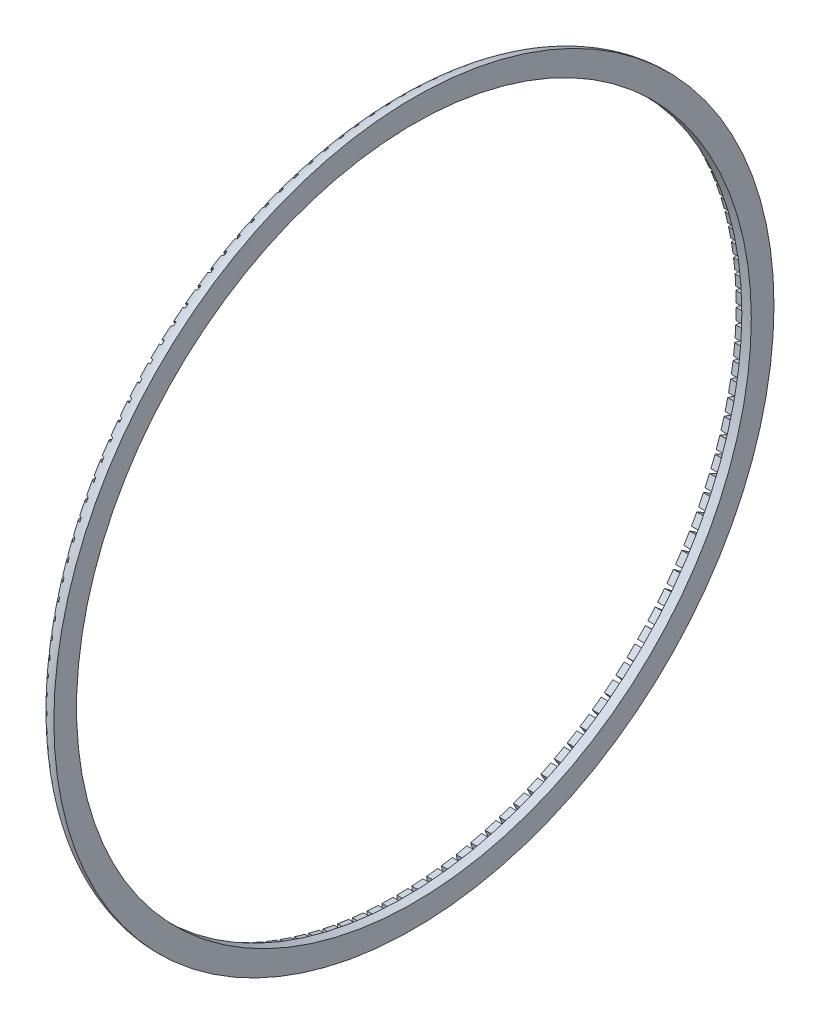
from build123d import *

# Parameters (mm, degrees)
CUT_EXTRUDE1_DEPTH = 3


with BuildPart() as part:
    # Sketch1 → Revolve1 (revolve)
    with BuildSketch(Plane.XY):
        with BuildLine():
            Line((-17.495417101, 23.232569393), (-16.995417101, 23.232569393))
            Line((-16.995417101, 23.232569393), (-16.995417101, 23.032569393))
            Line((-16.995417101, 23.032569393), (-16.495417101, 23.032569393))
            Line((-16.495417101, 23.032569393), (-16.495417101, 24.232569393))
            ThreePointArc((-16.495417101, 24.232569393), (-17.202523882, 23.939676175), (-17.495417101, 23.232569393))
        make_face()
    revolve(axis=Axis((-9.495417101, 5.185065564, 0), (-1, 0, 0)))

    # Sketch2 → Cut-Extrude1 (cut)
    with BuildSketch(Plane(origin=(-20, 0, 0), x_dir=(0, 0, -1), z_dir=(1, 0, 0))):
        with BuildLine():
            Line((0.1, 24.232569393), (0.1, 23.227252678))
            ThreePointArc((0.1, 23.227252678), (0, 23.127252678), (-0.1, 23.227252678))
            Line((-0.1, 23.227252678), (-0.1, 24.232569393))
            ThreePointArc((-0.1, 24.232569393), (0, 24.332569393), (0.1, 24.232569393))
        make_face()
        with BuildLine():
            Line((0.93074527, 24.210078452), (0.886893971, 23.205718575))
            ThreePointArc((0.886893971, 23.205718575), (0.78262721, 23.110175692), (0.687084326, 23.214442453))
            Line((0.687084326, 23.214442453), (0.730935626, 24.218802329))
            ThreePointArc((0.730935626, 24.218802329), (0.835202387, 24.314345212), (0.93074527, 24.210078452))
        make_face()
        with BuildLine():
            Line((1.759718814, 24.151372316), (1.672099689, 23.149881135))
            ThreePointArc((1.672099689, 23.149881135), (1.563764644, 23.058977239), (1.472860749, 23.167312283))
            Line((1.472860749, 23.167312283), (1.560479874, 24.168803465))
            ThreePointArc((1.560479874, 24.168803465), (1.668814918, 24.259707361), (1.759718814, 24.151372316))
        make_face()
        with BuildLine():
            Line((2.585342632, 24.056562738), (2.454122469, 23.059846647))
            ThreePointArc((2.454122469, 23.059846647), (2.341925364, 22.97375478), (2.255833497, 23.085951885))
            Line((2.255833497, 23.085951885), (2.38705366, 24.082667977))
            ThreePointArc((2.38705366, 24.082667977), (2.499250765, 24.168759844), (2.585342632, 24.056562738))
        make_face()
        with BuildLine():
            Line((3.406045104, 23.925830193), (3.231473689, 22.935786498))
            ThreePointArc((3.231473689, 22.935786498), (3.115628096, 22.85467054), (3.034512138, 22.970516133))
            Line((3.034512138, 22.970516133), (3.209083554, 23.960559828))
            ThreePointArc((3.209083554, 23.960559828), (3.324929147, 24.041675786), (3.406045104, 23.925830193))
        make_face()
        with BuildLine():
            Line((4.220263976, 23.759423537), (4.002673614, 22.777936842))
            ThreePointArc((4.002673614, 22.777936842), (3.883400052, 22.701951203), (3.807414413, 22.821224765))
            Line((3.807414413, 22.821224765), (4.025004775, 23.80271146))
            ThreePointArc((4.025004775, 23.80271146), (4.144278337, 23.878697099), (4.220263976, 23.759423537))
        make_face()
        with BuildLine():
            Line((5.026449335, 23.557659535), (4.766254223, 22.586598156))
            ThreePointArc((4.766254223, 22.586598156), (4.643779736, 22.515887478), (4.573069058, 22.638361965))
            Line((4.573069058, 22.638361965), (4.83326417, 23.609423344))
            ThreePointArc((4.83326417, 23.609423344), (4.955738657, 23.680134022), (5.026449335, 23.557659535))
        make_face()
        with BuildLine():
            Line((5.823066563, 23.320922256), (5.520761996, 22.362134663))
            ThreePointArc((5.520761996, 22.362134663), (5.395319721, 22.296833548), (5.330018606, 22.422275823))
            Line((5.330018606, 22.422275823), (5.632323173, 23.381063415))
            ThreePointArc((5.632323173, 23.381063415), (5.757765448, 23.446364531), (5.823066563, 23.320922256))
        make_face()
        with BuildLine():
            Line((6.608599252, 23.049662343), (6.264760685, 22.104973644))
            ThreePointArc((6.264760685, 22.104973644), (6.136589408, 22.045206396), (6.076822161, 22.173377672))
            Line((6.076822161, 22.173377672), (6.420660728, 23.118066371))
            ThreePointArc((6.420660728, 23.118066371), (6.548832004, 23.177833619), (6.608599252, 23.049662343))
        make_face()
        with BuildLine():
            Line((7.381552097, 22.744396154), (6.996834046, 21.815604617))
            ThreePointArc((6.996834046, 21.815604617), (6.866177749, 21.761485007), (6.812058139, 21.892141304))
            Line((6.812058139, 21.892141304), (7.19677619, 22.820932841))
            ThreePointArc((7.19677619, 22.820932841), (7.327432487, 22.875052451), (7.381552097, 22.744396154))
        make_face()
        with BuildLine():
            Line((8.140453738, 22.405704782), (7.715588535, 21.494578415))
            ThreePointArc((7.715588535, 21.494578415), (7.58269593, 21.446209462), (7.534326978, 21.579102067))
            Line((7.534326978, 21.579102067), (7.95919218, 22.490228434))
            ThreePointArc((7.95919218, 22.490228434), (8.092084785, 22.538597387), (8.140453738, 22.405704782))
        make_face()
        with BuildLine():
            Line((8.883859562, 22.034232944), (8.419655963, 21.142506127))
            ThreePointArc((8.419655963, 21.142506127), (8.284780018, 21.099979905), (8.242253796, 21.23485585))
            Line((8.242253796, 21.23485585), (8.706457396, 22.126582667))
            ThreePointArc((8.706457396, 22.126582667), (8.84133334, 22.169108889), (8.883859562, 22.034232944))
        make_face()
        with BuildLine():
            Line((9.610354455, 21.630687759), (9.107696098, 20.760057945))
            ThreePointArc((9.107696098, 20.760057945), (8.971093557, 20.723455404), (8.934491017, 20.860057945))
            Line((8.934491017, 20.860057945), (9.437149374, 21.730687759))
            ThreePointArc((9.437149374, 21.730687759), (9.573751915, 21.767290299), (9.610354455, 21.630687759))
        make_face()
        with BuildLine():
            Line((10.318555492, 21.195837397), (9.778399215, 20.347961879))
            ThreePointArc((9.778399215, 20.347961879), (9.640330109, 20.317352695), (9.609720926, 20.455421801))
            Line((9.609720926, 20.455421801), (10.149877203, 21.303297319))
            ThreePointArc((10.149877203, 21.303297319), (10.287946308, 21.333906502), (10.318555492, 21.195837397))
        make_face()
        with BuildLine():
            Line((11.007114572, 20.730509621), (10.430488593, 19.907002378))
            ThreePointArc((10.430488593, 19.907002378), (10.291215745, 19.882444818), (10.266658185, 20.021717666))
            Line((10.266658185, 20.021717666), (10.843284163, 20.845224908))
            ThreePointArc((10.843284163, 20.845224908), (10.982557012, 20.869782469), (11.007114572, 20.730509621))
        make_face()
        with BuildLine():
            Line((11.674720984, 20.235590208), (11.062722944, 19.438018834))
            ThreePointArc((11.062722944, 19.438018834), (10.922511467, 19.419559643), (10.904052276, 19.55977112))
            Line((10.904052276, 19.55977112), (11.516050316, 20.357342494))
            ThreePointArc((11.516050316, 20.357342494), (11.656261793, 20.375801685), (11.674720984, 20.235590208))
        make_face()
        with BuildLine():
            Line((12.320103901, 19.712021267), (11.673898773, 18.941903983))
            ThreePointArc((11.673898773, 18.941903983), (11.533015568, 18.9295783), (11.520689884, 19.070461505))
            Line((11.520689884, 19.070461505), (12.166895013, 19.840578789))
            ThreePointArc((12.166895013, 19.840578789), (12.307778218, 19.852904472), (12.320103901, 19.712021267))
        make_face()
        with BuildLine():
            Line((12.9420348, 19.160799439), (12.262852672, 18.419602209))
            ThreePointArc((12.262852672, 18.419602209), (12.121565918, 18.413433496), (12.115397205, 18.55472025))
            Line((12.115397205, 18.55472025), (12.794579333, 19.295917481))
            ThreePointArc((12.794579333, 19.295917481), (12.935866088, 19.302086194), (12.9420348, 19.160799439))
        make_face()
        with BuildLine():
            Line((13.539329801, 18.582974008), (12.828463534, 17.872107742))
            ThreePointArc((12.828463534, 17.872107742), (12.687042178, 17.872107742), (12.687042178, 18.013529098))
            Line((12.687042178, 18.013529098), (13.397908444, 18.724395365))
            ThreePointArc((13.397908444, 18.724395365), (13.539329801, 18.724395365), (13.539329801, 18.582974008))
        make_face()
        with BuildLine():
            Line((14.110851917, 17.979644897), (13.369654687, 17.300462769))
            ThreePointArc((13.369654687, 17.300462769), (13.228367932, 17.306631481), (13.234536645, 17.447918236))
            Line((13.234536645, 17.447918236), (13.975733876, 18.127100364))
            ThreePointArc((13.975733876, 18.127100364), (14.11702063, 18.120931651), (14.110851917, 17.979644897))
        make_face()
        with BuildLine():
            Line((14.655513225, 17.351960577), (13.885395942, 16.705755448))
            ThreePointArc((13.885395942, 16.705755448), (13.744512736, 16.718081132), (13.75683842, 16.858964337))
            Line((13.75683842, 16.858964337), (14.526955703, 17.505169465))
            ThreePointArc((14.526955703, 17.505169465), (14.667838908, 17.492843782), (14.655513225, 17.351960577))
        make_face()
        with BuildLine():
            Line((15.17227693, 16.70111588), (14.374705556, 16.08911784))
            ThreePointArc((14.374705556, 16.08911784), (14.234494079, 16.107577031), (14.25295327, 16.247788508))
            Line((14.25295327, 16.247788508), (15.050524644, 16.859786548))
            ThreePointArc((15.050524644, 16.859786548), (15.190736121, 16.841327357), (15.17227693, 16.70111588))
        make_face()
        with BuildLine():
            Line((15.660159344, 16.028349727), (14.836652102, 15.451723748))
            ThreePointArc((14.836652102, 15.451723748), (14.697379254, 15.476281309), (14.721936814, 15.615554157))
            Line((14.721936814, 15.615554157), (15.545444057, 16.192180136))
            ThreePointArc((15.545444057, 16.192180136), (15.684716905, 16.167622575), (15.660159344, 16.028349727))
        make_face()
        with BuildLine():
            Line((16.118231755, 15.334942767), (15.270356237, 14.794786489))
            ThreePointArc((15.270356237, 14.794786489), (15.132287131, 14.825395673), (15.162896315, 14.963464779))
            Line((15.162896315, 14.963464779), (16.010771833, 15.503621056))
            ThreePointArc((16.010771833, 15.503621056), (16.148840938, 15.473011872), (16.118231755, 15.334942767))
        make_face()
        with BuildLine():
            Line((16.545622195, 14.622214938), (15.674992381, 14.119556581))
            ThreePointArc((15.674992381, 14.119556581), (15.53838984, 14.156159121), (15.574992381, 14.292761661))
            Line((15.574992381, 14.292761661), (16.445622195, 14.795420019))
            ThreePointArc((16.445622195, 14.795420019), (16.582224735, 14.758817479), (16.545622195, 14.622214938))
        make_face()
        with BuildLine():
            Line((16.941517103, 13.891522959), (16.049790286, 13.42731936))
            ThreePointArc((16.049790286, 13.42731936), (15.914914341, 13.469845582), (15.957440563, 13.604721527))
            Line((15.957440563, 13.604721527), (16.84916738, 14.068925126))
            ThreePointArc((16.84916738, 14.068925126), (16.984043325, 14.026398904), (16.941517103, 13.891522959))
        make_face()
        with BuildLine():
            Line((17.30516287, 13.144257744), (16.394036503, 12.719392541))
            ThreePointArc((16.394036503, 12.719392541), (16.261143898, 12.767761494), (16.309512851, 12.900654099))
            Line((16.309512851, 12.900654099), (17.220639218, 13.325519302))
            ThreePointArc((17.220639218, 13.325519302), (17.353531823, 13.277150349), (17.30516287, 13.144257744))
        make_face()
        with BuildLine():
            Line((17.635867277, 12.381841754), (16.70707574, 11.997123703))
            ThreePointArc((16.70707574, 11.997123703), (16.576419443, 12.051243313), (16.630539053, 12.181899609))
            Line((16.630539053, 12.181899609), (17.55933059, 12.566617661))
            ThreePointArc((17.55933059, 12.566617661), (17.689986887, 12.512498051), (17.635867277, 12.381841754))
        make_face()
        with BuildLine():
            Line((17.933000807, 11.605726292), (16.988312108, 11.261887725))
            ThreePointArc((16.988312108, 11.261887725), (16.860140832, 11.321654972), (16.91990808, 11.449826249))
            Line((16.91990808, 11.449826249), (17.864596779, 11.793664816))
            ThreePointArc((17.864596779, 11.793664816), (17.992768055, 11.733897568), (17.933000807, 11.605726292))
        make_face()
        with BuildLine():
            Line((18.195997852, 10.817388736), (17.237210259, 10.51508417))
            ThreePointArc((17.237210259, 10.51508417), (17.111767984, 10.580385285), (17.177069099, 10.70582756))
            Line((17.177069099, 10.70582756), (18.135856692, 11.008132127))
            ThreePointArc((18.135856692, 11.008132127), (18.261298967, 10.942831011), (18.195997852, 10.817388736))
        make_face()
        with BuildLine():
            Line((18.42435778, 10.018329734), (17.453296401, 9.758134622))
            ThreePointArc((17.453296401, 9.758134622), (17.330821914, 9.8288453), (17.401532592, 9.951319787))
            Line((17.401532592, 9.951319787), (18.372593971, 10.211514899))
            ThreePointArc((18.372593971, 10.211514899), (18.495068458, 10.140804221), (18.42435778, 10.018329734))
        make_face()
        with BuildLine():
            Line((18.617645896, 9.210070339), (17.636159201, 8.992479977))
            ThreePointArc((17.636159201, 8.992479977), (17.516885639, 9.068465616), (17.592871278, 9.187739178))
            Line((17.592871278, 9.187739178), (18.574357973, 9.40532954))
            ThreePointArc((18.574357973, 9.40532954), (18.693631535, 9.329343901), (18.617645896, 9.210070339))
        make_face()
        with BuildLine():
            Line((18.775494265, 8.394149118), (17.785450569, 8.219577702))
            ThreePointArc((17.785450569, 8.219577702), (17.669604976, 8.30069366), (17.750720934, 8.416539253))
            Line((17.750720934, 8.416539253), (18.740764629, 8.591110668))
            ThreePointArc((18.740764629, 8.591110668), (18.856610222, 8.509994711), (18.775494265, 8.394149118))
        make_face()
        with BuildLine():
            Line((18.897602413, 7.572119224), (17.900886322, 7.440899061))
            ThreePointArc((17.900886322, 7.440899061), (17.788689216, 7.526990928), (17.874781083, 7.639188033))
            Line((17.874781083, 7.639188033), (18.871497175, 7.770408196))
            ThreePointArc((18.871497175, 7.770408196), (18.98369428, 7.684316329), (18.897602413, 7.572119224))
        make_face()
        with BuildLine():
            Line((18.983737901, 6.745545438), (17.982246719, 6.657926313))
            ThreePointArc((17.982246719, 6.657926313), (17.873911675, 6.748830208), (17.964815571, 6.857165252))
            Line((17.964815571, 6.857165252), (18.966306753, 6.944784377))
            ThreePointArc((18.966306753, 6.944784377), (19.074641797, 6.853880482), (18.983737901, 6.745545438))
        make_face()
        with BuildLine():
            Line((19.033736765, 5.91600119), (18.029376889, 5.87214989))
            ThreePointArc((18.029376889, 5.87214989), (17.925110128, 5.967692774), (18.020653011, 6.071959535))
            Line((18.020653011, 6.071959535), (19.025012888, 6.115810834))
            ThreePointArc((19.025012888, 6.115810834), (19.129279649, 6.02026795), (19.033736765, 5.91600119))
        make_face()
        with BuildLine():
            Line((19.04750383, 5.085065564), (18.042187114, 5.085065564))
            ThreePointArc((18.042187114, 5.085065564), (17.942187114, 5.185065564), (18.042187114, 5.285065564))
            Line((18.042187114, 5.285065564), (19.04750383, 5.285065564))
            ThreePointArc((19.04750383, 5.285065564), (19.14750383, 5.185065564), (19.04750383, 5.085065564))
        make_face()
        with BuildLine():
            Line((19.025012888, 4.254320294), (18.020653011, 4.298171593))
            ThreePointArc((18.020653011, 4.298171593), (17.925110128, 4.402438354), (18.029376889, 4.497981237))
            Line((18.029376889, 4.497981237), (19.033736765, 4.454129938))
            ThreePointArc((19.033736765, 4.454129938), (19.129279649, 4.349863177), (19.025012888, 4.254320294))
        make_face()
        with BuildLine():
            Line((18.966306753, 3.42534675), (17.964815571, 3.512965875))
            ThreePointArc((17.964815571, 3.512965875), (17.873911675, 3.621300919), (17.982246719, 3.712204815))
            Line((17.982246719, 3.712204815), (18.983737901, 3.62458569))
            ThreePointArc((18.983737901, 3.62458569), (19.074641797, 3.516250646), (18.966306753, 3.42534675))
        make_face()
        with BuildLine():
            Line((18.871497175, 2.599722932), (17.874781083, 2.730943094))
            ThreePointArc((17.874781083, 2.730943094), (17.788689216, 2.8431402), (17.900886322, 2.929232067))
            Line((17.900886322, 2.929232067), (18.897602413, 2.798011904))
            ThreePointArc((18.897602413, 2.798011904), (18.98369428, 2.685814798), (18.871497175, 2.599722932))
        make_face()
        with BuildLine():
            Line((18.740764629, 1.779020459), (17.750720934, 1.953591875))
            ThreePointArc((17.750720934, 1.953591875), (17.669604976, 2.069437468), (17.785450569, 2.150553426))
            Line((17.785450569, 2.150553426), (18.775494265, 1.97598201))
            ThreePointArc((18.775494265, 1.97598201), (18.856610222, 1.860136417), (18.740764629, 1.779020459))
        make_face()
        with BuildLine():
            Line((18.574357973, 0.964801588), (17.592871278, 1.18239195))
            ThreePointArc((17.592871278, 1.18239195), (17.516885639, 1.301665512), (17.636159201, 1.377651151))
            Line((17.636159201, 1.377651151), (18.617645896, 1.160060789))
            ThreePointArc((18.617645896, 1.160060789), (18.693631535, 1.040787227), (18.574357973, 0.964801588))
        make_face()
        with BuildLine():
            Line((18.372593971, 0.158616228), (17.401532592, 0.418811341))
            ThreePointArc((17.401532592, 0.418811341), (17.330821914, 0.541285828), (17.453296401, 0.611996506))
            Line((17.453296401, 0.611996506), (18.42435778, 0.351801394))
            ThreePointArc((18.42435778, 0.351801394), (18.495068458, 0.229326907), (18.372593971, 0.158616228))
        make_face()
        with BuildLine():
            Line((18.135856692, -0.638000999), (17.177069099, -0.335696432))
            ThreePointArc((17.177069099, -0.335696432), (17.111767984, -0.210254157), (17.237210259, -0.144953042))
            Line((17.237210259, -0.144953042), (18.195997852, -0.447257609))
            ThreePointArc((18.195997852, -0.447257609), (18.261298967, -0.572699884), (18.135856692, -0.638000999))
        make_face()
        with BuildLine():
            Line((17.864596779, -1.423533688), (16.91990808, -1.079695121))
            ThreePointArc((16.91990808, -1.079695121), (16.860140832, -0.951523845), (16.988312108, -0.891756597))
            Line((16.988312108, -0.891756597), (17.933000807, -1.235595164))
            ThreePointArc((17.933000807, -1.235595164), (17.992768055, -1.36376644), (17.864596779, -1.423533688))
        make_face()
        with BuildLine():
            Line((17.55933059, -2.196486533), (16.630539053, -1.811768482))
            ThreePointArc((16.630539053, -1.811768482), (16.576419443, -1.681112185), (16.70707574, -1.626992575))
            Line((16.70707574, -1.626992575), (17.635867277, -2.011710626))
            ThreePointArc((17.635867277, -2.011710626), (17.689986887, -2.142366923), (17.55933059, -2.196486533))
        make_face()
        with BuildLine():
            Line((17.220639218, -2.955388174), (16.309512851, -2.530522971))
            ThreePointArc((16.309512851, -2.530522971), (16.261143898, -2.397630366), (16.394036503, -2.349261414))
            Line((16.394036503, -2.349261414), (17.30516287, -2.774126616))
            ThreePointArc((17.30516287, -2.774126616), (17.353531823, -2.907019221), (17.220639218, -2.955388174))
        make_face()
        with BuildLine():
            Line((16.84916738, -3.698793998), (15.957440563, -3.234590399))
            ThreePointArc((15.957440563, -3.234590399), (15.914914341, -3.099714455), (16.049790286, -3.057188233))
            Line((16.049790286, -3.057188233), (16.941517103, -3.521391832))
            ThreePointArc((16.941517103, -3.521391832), (16.984043325, -3.656267776), (16.84916738, -3.698793998))
        make_face()
        with BuildLine():
            Line((16.445622195, -4.425288891), (15.574992381, -3.922630534))
            ThreePointArc((15.574992381, -3.922630534), (15.53838984, -3.786027993), (15.674992381, -3.749425453))
            Line((15.674992381, -3.749425453), (16.545622195, -4.252083811))
            ThreePointArc((16.545622195, -4.252083811), (16.582224735, -4.388686351), (16.445622195, -4.425288891))
        make_face()
        with BuildLine():
            Line((16.010771833, -5.133489928), (15.162896315, -4.593333651))
            ThreePointArc((15.162896315, -4.593333651), (15.132287131, -4.455264546), (15.270356237, -4.424655362))
            Line((15.270356237, -4.424655362), (16.118231755, -4.964811639))
            ThreePointArc((16.118231755, -4.964811639), (16.148840938, -5.102880745), (16.010771833, -5.133489928))
        make_face()
        with BuildLine():
            Line((15.545444057, -5.822049008), (14.721936814, -5.24542303))
            ThreePointArc((14.721936814, -5.24542303), (14.697379254, -5.106150181), (14.836652102, -5.081592621))
            Line((14.836652102, -5.081592621), (15.660159344, -5.6582186))
            ThreePointArc((15.660159344, -5.6582186), (15.684716905, -5.797491448), (15.545444057, -5.822049008))
        make_face()
        with BuildLine():
            Line((15.050524644, -6.48965542), (14.25295327, -5.87765738))
            ThreePointArc((14.25295327, -5.87765738), (14.234494079, -5.737445903), (14.374705556, -5.718986712))
            Line((14.374705556, -5.718986712), (15.17227693, -6.330984752))
            ThreePointArc((15.17227693, -6.330984752), (15.190736121, -6.471196229), (15.050524644, -6.48965542))
        make_face()
        with BuildLine():
            Line((14.526955703, -7.135038338), (13.75683842, -6.488833209))
            ThreePointArc((13.75683842, -6.488833209), (13.744512736, -6.347950004), (13.885395942, -6.335624321))
            Line((13.885395942, -6.335624321), (14.655513225, -6.981829449))
            ThreePointArc((14.655513225, -6.981829449), (14.667838908, -7.122712654), (14.526955703, -7.135038338))
        make_face()
        with BuildLine():
            Line((13.975733876, -7.756969237), (13.234536645, -7.077787108))
            ThreePointArc((13.234536645, -7.077787108), (13.228367932, -6.936500354), (13.369654687, -6.930331641))
            Line((13.369654687, -6.930331641), (14.110851917, -7.609513769))
            ThreePointArc((14.110851917, -7.609513769), (14.11702063, -7.750800524), (13.975733876, -7.756969237))
        make_face()
        with BuildLine():
            Line((13.397908444, -8.354264237), (12.687042178, -7.64339797))
            ThreePointArc((12.687042178, -7.64339797), (12.687042178, -7.501976614), (12.828463534, -7.501976614))
            Line((12.828463534, -7.501976614), (13.539329801, -8.212842881))
            ThreePointArc((13.539329801, -8.212842881), (13.539329801, -8.354264237), (13.397908444, -8.354264237))
        make_face()
        with BuildLine():
            Line((12.794579333, -8.925786353), (12.115397205, -8.184589123))
            ThreePointArc((12.115397205, -8.184589123), (12.121565918, -8.043302368), (12.262852672, -8.049471081))
            Line((12.262852672, -8.049471081), (12.9420348, -8.790668312))
            ThreePointArc((12.9420348, -8.790668312), (12.935866088, -8.931955066), (12.794579333, -8.925786353))
        make_face()
        with BuildLine():
            Line((12.166895013, -9.470447661), (11.520689884, -8.700330378))
            ThreePointArc((11.520689884, -8.700330378), (11.533015568, -8.559447172), (11.673898773, -8.571772856))
            Line((11.673898773, -8.571772856), (12.320103901, -9.341890139))
            ThreePointArc((12.320103901, -9.341890139), (12.307778218, -9.482773344), (12.166895013, -9.470447661))
        make_face()
        with BuildLine():
            Line((11.516050316, -9.987211366), (10.904052276, -9.189639992))
            ThreePointArc((10.904052276, -9.189639992), (10.922511467, -9.049428515), (11.062722944, -9.067887706))
            Line((11.062722944, -9.067887706), (11.674720984, -9.865459081))
            ThreePointArc((11.674720984, -9.865459081), (11.656261793, -10.005670558), (11.516050316, -9.987211366))
        make_face()
        with BuildLine():
            Line((10.843284163, -10.47509378), (10.266658185, -9.651586538))
            ThreePointArc((10.266658185, -9.651586538), (10.291215745, -9.51231369), (10.430488593, -9.536871251))
            Line((10.430488593, -9.536871251), (11.007114572, -10.360378493))
            ThreePointArc((11.007114572, -10.360378493), (10.982557012, -10.499651341), (10.843284163, -10.47509378))
        make_face()
        with BuildLine():
            Line((10.149877203, -10.933166191), (9.609720926, -10.085290673))
            ThreePointArc((9.609720926, -10.085290673), (9.640330109, -9.947221567), (9.778399215, -9.977830751))
            Line((9.778399215, -9.977830751), (10.318555492, -10.825706269))
            ThreePointArc((10.318555492, -10.825706269), (10.287946308, -10.963775375), (10.149877203, -10.933166191))
        make_face()
        with BuildLine():
            Line((9.437149374, -11.360556631), (8.934491017, -10.489926817))
            ThreePointArc((8.934491017, -10.489926817), (8.971093557, -10.353324277), (9.107696098, -10.389926817))
            Line((9.107696098, -10.389926817), (9.610354455, -11.260556631))
            ThreePointArc((9.610354455, -11.260556631), (9.573751915, -11.397159172), (9.437149374, -11.360556631))
        make_face()
        with BuildLine():
            Line((8.706457396, -11.756451539), (8.242253796, -10.864724722))
            ThreePointArc((8.242253796, -10.864724722), (8.284780018, -10.729848777), (8.419655963, -10.772374999))
            Line((8.419655963, -10.772374999), (8.883859562, -11.664101817))
            ThreePointArc((8.883859562, -11.664101817), (8.84133334, -11.798977761), (8.706457396, -11.756451539))
        make_face()
        with BuildLine():
            Line((7.95919218, -12.120097307), (7.534326978, -11.208970939))
            ThreePointArc((7.534326978, -11.208970939), (7.58269593, -11.076078334), (7.715588535, -11.124447287))
            Line((7.715588535, -11.124447287), (8.140453738, -12.035573654))
            ThreePointArc((8.140453738, -12.035573654), (8.092084785, -12.168466259), (7.95919218, -12.120097307))
        make_face()
        with BuildLine():
            Line((7.19677619, -12.450801713), (6.812058139, -11.522010176))
            ThreePointArc((6.812058139, -11.522010176), (6.866177749, -11.391353879), (6.996834046, -11.445473489))
            Line((6.996834046, -11.445473489), (7.381552097, -12.374265026))
            ThreePointArc((7.381552097, -12.374265026), (7.327432487, -12.504921323), (7.19677619, -12.450801713))
        make_face()
        with BuildLine():
            Line((6.420660728, -12.747935243), (6.076822161, -11.803246545))
            ThreePointArc((6.076822161, -11.803246545), (6.136589408, -11.675075268), (6.264760685, -11.734842516))
            Line((6.264760685, -11.734842516), (6.608599252, -12.679531215))
            ThreePointArc((6.608599252, -12.679531215), (6.548832004, -12.807702491), (6.420660728, -12.747935243))
        make_face()
        with BuildLine():
            Line((5.632323173, -13.010932288), (5.330018606, -12.052144696))
            ThreePointArc((5.330018606, -12.052144696), (5.395319721, -11.92670242), (5.520761996, -11.992003536))
            Line((5.520761996, -11.992003536), (5.823066563, -12.950791128))
            ThreePointArc((5.823066563, -12.950791128), (5.757765448, -13.076233403), (5.632323173, -13.010932288))
        make_face()
        with BuildLine():
            Line((4.83326417, -13.239292216), (4.573069058, -12.268230837))
            ThreePointArc((4.573069058, -12.268230837), (4.643779736, -12.14575635), (4.766254223, -12.216467028))
            Line((4.766254223, -12.216467028), (5.026449335, -13.187528407))
            ThreePointArc((5.026449335, -13.187528407), (4.955738657, -13.310002894), (4.83326417, -13.239292216))
        make_face()
        with BuildLine():
            Line((4.025004775, -13.432580332), (3.807414413, -12.451093637))
            ThreePointArc((3.807414413, -12.451093637), (3.883400052, -12.331820075), (4.002673614, -12.407805714))
            Line((4.002673614, -12.407805714), (4.220263976, -13.389292409))
            ThreePointArc((4.220263976, -13.389292409), (4.144278337, -13.508565971), (4.025004775, -13.432580332))
        make_face()
        with BuildLine():
            Line((3.209083554, -13.590428701), (3.034512138, -12.600385005))
            ThreePointArc((3.034512138, -12.600385005), (3.115628096, -12.484539412), (3.231473689, -12.56565537))
            Line((3.231473689, -12.56565537), (3.406045104, -13.555699065))
            ThreePointArc((3.406045104, -13.555699065), (3.324929147, -13.671544658), (3.209083554, -13.590428701))
        make_face()
        with BuildLine():
            Line((2.38705366, -13.712536849), (2.255833497, -12.715820758))
            ThreePointArc((2.255833497, -12.715820758), (2.341925364, -12.603623652), (2.454122469, -12.689715519))
            Line((2.454122469, -12.689715519), (2.585342632, -13.686431611))
            ThreePointArc((2.585342632, -13.686431611), (2.499250765, -13.798628716), (2.38705366, -13.712536849))
        make_face()
        with BuildLine():
            Line((1.560479874, -13.798672337), (1.472860749, -12.797181156))
            ThreePointArc((1.472860749, -12.797181156), (1.563764644, -12.688846112), (1.672099689, -12.779750007))
            Line((1.672099689, -12.779750007), (1.759718814, -13.781241189))
            ThreePointArc((1.759718814, -13.781241189), (1.668814918, -13.889576233), (1.560479874, -13.798672337))
        make_face()
        with BuildLine():
            Line((0.730935626, -13.848671201), (0.687084326, -12.844311325))
            ThreePointArc((0.687084326, -12.844311325), (0.78262721, -12.740044564), (0.886893971, -12.835587447))
            Line((0.886893971, -12.835587447), (0.93074527, -13.839947324))
            ThreePointArc((0.93074527, -13.839947324), (0.835202387, -13.944214085), (0.730935626, -13.848671201))
        make_face()
        with BuildLine():
            Line((-0.1, -13.862438266), (-0.1, -12.85712155))
            ThreePointArc((-0.1, -12.85712155), (0, -12.75712155), (0.1, -12.85712155))
            Line((0.1, -12.85712155), (0.1, -13.862438266))
            ThreePointArc((0.1, -13.862438266), (0, -13.962438266), (-0.1, -13.862438266))
        make_face()
        with BuildLine():
            Line((-0.93074527, -13.839947324), (-0.886893971, -12.835587447))
            ThreePointArc((-0.886893971, -12.835587447), (-0.78262721, -12.740044564), (-0.687084326, -12.844311325))
            Line((-0.687084326, -12.844311325), (-0.730935626, -13.848671201))
            ThreePointArc((-0.730935626, -13.848671201), (-0.835202387, -13.944214085), (-0.93074527, -13.839947324))
        make_face()
        with BuildLine():
            Line((-1.759718814, -13.781241189), (-1.672099689, -12.779750007))
            ThreePointArc((-1.672099689, -12.779750007), (-1.563764644, -12.688846112), (-1.472860749, -12.797181156))
            Line((-1.472860749, -12.797181156), (-1.560479874, -13.798672337))
            ThreePointArc((-1.560479874, -13.798672337), (-1.668814918, -13.889576233), (-1.759718814, -13.781241189))
        make_face()
        with BuildLine():
            Line((-2.585342632, -13.686431611), (-2.454122469, -12.689715519))
            ThreePointArc((-2.454122469, -12.689715519), (-2.341925364, -12.603623652), (-2.255833497, -12.715820758))
            Line((-2.255833497, -12.715820758), (-2.38705366, -13.712536849))
            ThreePointArc((-2.38705366, -13.712536849), (-2.499250765, -13.798628716), (-2.585342632, -13.686431611))
        make_face()
        with BuildLine():
            Line((-3.406045104, -13.555699065), (-3.231473689, -12.56565537))
            ThreePointArc((-3.231473689, -12.56565537), (-3.115628096, -12.484539412), (-3.034512138, -12.600385005))
            Line((-3.034512138, -12.600385005), (-3.209083554, -13.590428701))
            ThreePointArc((-3.209083554, -13.590428701), (-3.324929147, -13.671544658), (-3.406045104, -13.555699065))
        make_face()
        with BuildLine():
            Line((-4.220263976, -13.389292409), (-4.002673614, -12.407805714))
            ThreePointArc((-4.002673614, -12.407805714), (-3.883400052, -12.331820075), (-3.807414413, -12.451093637))
            Line((-3.807414413, -12.451093637), (-4.025004775, -13.432580332))
            ThreePointArc((-4.025004775, -13.432580332), (-4.144278337, -13.508565971), (-4.220263976, -13.389292409))
        make_face()
        with BuildLine():
            Line((-5.026449335, -13.187528407), (-4.766254223, -12.216467028))
            ThreePointArc((-4.766254223, -12.216467028), (-4.643779736, -12.14575635), (-4.573069058, -12.268230837))
            Line((-4.573069058, -12.268230837), (-4.83326417, -13.239292216))
            ThreePointArc((-4.83326417, -13.239292216), (-4.955738657, -13.310002894), (-5.026449335, -13.187528407))
        make_face()
        with BuildLine():
            Line((-5.823066563, -12.950791128), (-5.520761996, -11.992003536))
            ThreePointArc((-5.520761996, -11.992003536), (-5.395319721, -11.92670242), (-5.330018606, -12.052144696))
            Line((-5.330018606, -12.052144696), (-5.632323173, -13.010932288))
            ThreePointArc((-5.632323173, -13.010932288), (-5.757765448, -13.076233403), (-5.823066563, -12.950791128))
        make_face()
        with BuildLine():
            Line((-6.608599252, -12.679531215), (-6.264760685, -11.734842516))
            ThreePointArc((-6.264760685, -11.734842516), (-6.136589408, -11.675075268), (-6.076822161, -11.803246545))
            Line((-6.076822161, -11.803246545), (-6.420660728, -12.747935243))
            ThreePointArc((-6.420660728, -12.747935243), (-6.548832004, -12.807702491), (-6.608599252, -12.679531215))
        make_face()
        with BuildLine():
            Line((-7.381552097, -12.374265026), (-6.996834046, -11.445473489))
            ThreePointArc((-6.996834046, -11.445473489), (-6.866177749, -11.391353879), (-6.812058139, -11.522010176))
            Line((-6.812058139, -11.522010176), (-7.19677619, -12.450801713))
            ThreePointArc((-7.19677619, -12.450801713), (-7.327432487, -12.504921323), (-7.381552097, -12.374265026))
        make_face()
        with BuildLine():
            Line((-8.140453738, -12.035573654), (-7.715588535, -11.124447287))
            ThreePointArc((-7.715588535, -11.124447287), (-7.58269593, -11.076078334), (-7.534326978, -11.208970939))
            Line((-7.534326978, -11.208970939), (-7.95919218, -12.120097307))
            ThreePointArc((-7.95919218, -12.120097307), (-8.092084785, -12.168466259), (-8.140453738, -12.035573654))
        make_face()
        with BuildLine():
            Line((-8.883859562, -11.664101817), (-8.419655963, -10.772374999))
            ThreePointArc((-8.419655963, -10.772374999), (-8.284780018, -10.729848777), (-8.242253796, -10.864724722))
            Line((-8.242253796, -10.864724722), (-8.706457396, -11.756451539))
            ThreePointArc((-8.706457396, -11.756451539), (-8.84133334, -11.798977761), (-8.883859562, -11.664101817))
        make_face()
        with BuildLine():
            Line((-9.610354455, -11.260556631), (-9.107696098, -10.389926817))
            ThreePointArc((-9.107696098, -10.389926817), (-8.971093557, -10.353324277), (-8.934491017, -10.489926817))
            Line((-8.934491017, -10.489926817), (-9.437149374, -11.360556631))
            ThreePointArc((-9.437149374, -11.360556631), (-9.573751915, -11.397159172), (-9.610354455, -11.260556631))
        make_face()
        with BuildLine():
            Line((-10.318555492, -10.825706269), (-9.778399215, -9.977830751))
            ThreePointArc((-9.778399215, -9.977830751), (-9.640330109, -9.947221567), (-9.609720926, -10.085290673))
            Line((-9.609720926, -10.085290673), (-10.149877203, -10.933166191))
            ThreePointArc((-10.149877203, -10.933166191), (-10.287946308, -10.963775375), (-10.318555492, -10.825706269))
        make_face()
        with BuildLine():
            Line((-11.007114572, -10.360378493), (-10.430488593, -9.536871251))
            ThreePointArc((-10.430488593, -9.536871251), (-10.291215745, -9.51231369), (-10.266658185, -9.651586538))
            Line((-10.266658185, -9.651586538), (-10.843284163, -10.47509378))
            ThreePointArc((-10.843284163, -10.47509378), (-10.982557012, -10.499651341), (-11.007114572, -10.360378493))
        make_face()
        with BuildLine():
            Line((-11.674720984, -9.865459081), (-11.062722944, -9.067887706))
            ThreePointArc((-11.062722944, -9.067887706), (-10.922511467, -9.049428515), (-10.904052276, -9.189639992))
            Line((-10.904052276, -9.189639992), (-11.516050316, -9.987211366))
            ThreePointArc((-11.516050316, -9.987211366), (-11.656261793, -10.005670558), (-11.674720984, -9.865459081))
        make_face()
        with BuildLine():
            Line((-12.320103901, -9.341890139), (-11.673898773, -8.571772856))
            ThreePointArc((-11.673898773, -8.571772856), (-11.533015568, -8.559447172), (-11.520689884, -8.700330378))
            Line((-11.520689884, -8.700330378), (-12.166895013, -9.470447661))
            ThreePointArc((-12.166895013, -9.470447661), (-12.307778218, -9.482773344), (-12.320103901, -9.341890139))
        make_face()
        with BuildLine():
            Line((-12.9420348, -8.790668312), (-12.262852672, -8.049471081))
            ThreePointArc((-12.262852672, -8.049471081), (-12.121565918, -8.043302368), (-12.115397205, -8.184589123))
            Line((-12.115397205, -8.184589123), (-12.794579333, -8.925786353))
            ThreePointArc((-12.794579333, -8.925786353), (-12.935866088, -8.931955066), (-12.9420348, -8.790668312))
        make_face()
        with BuildLine():
            Line((-13.539329801, -8.212842881), (-12.828463534, -7.501976614))
            ThreePointArc((-12.828463534, -7.501976614), (-12.687042178, -7.501976614), (-12.687042178, -7.64339797))
            Line((-12.687042178, -7.64339797), (-13.397908444, -8.354264237))
            ThreePointArc((-13.397908444, -8.354264237), (-13.539329801, -8.354264237), (-13.539329801, -8.212842881))
        make_face()
        with BuildLine():
            Line((-14.110851917, -7.609513769), (-13.369654687, -6.930331641))
            ThreePointArc((-13.369654687, -6.930331641), (-13.228367932, -6.936500354), (-13.234536645, -7.077787108))
            Line((-13.234536645, -7.077787108), (-13.975733876, -7.756969237))
            ThreePointArc((-13.975733876, -7.756969237), (-14.11702063, -7.750800524), (-14.110851917, -7.609513769))
        make_face()
        with BuildLine():
            Line((-14.655513225, -6.981829449), (-13.885395942, -6.335624321))
            ThreePointArc((-13.885395942, -6.335624321), (-13.744512736, -6.347950004), (-13.75683842, -6.488833209))
            Line((-13.75683842, -6.488833209), (-14.526955703, -7.135038338))
            ThreePointArc((-14.526955703, -7.135038338), (-14.667838908, -7.122712654), (-14.655513225, -6.981829449))
        make_face()
        with BuildLine():
            Line((-15.17227693, -6.330984752), (-14.374705556, -5.718986712))
            ThreePointArc((-14.374705556, -5.718986712), (-14.234494079, -5.737445903), (-14.25295327, -5.87765738))
            Line((-14.25295327, -5.87765738), (-15.050524644, -6.48965542))
            ThreePointArc((-15.050524644, -6.48965542), (-15.190736121, -6.471196229), (-15.17227693, -6.330984752))
        make_face()
        with BuildLine():
            Line((-15.660159344, -5.6582186), (-14.836652102, -5.081592621))
            ThreePointArc((-14.836652102, -5.081592621), (-14.697379254, -5.106150181), (-14.721936814, -5.24542303))
            Line((-14.721936814, -5.24542303), (-15.545444057, -5.822049008))
            ThreePointArc((-15.545444057, -5.822049008), (-15.684716905, -5.797491448), (-15.660159344, -5.6582186))
        make_face()
        with BuildLine():
            Line((-16.118231755, -4.964811639), (-15.270356237, -4.424655362))
            ThreePointArc((-15.270356237, -4.424655362), (-15.132287131, -4.455264546), (-15.162896315, -4.593333651))
            Line((-15.162896315, -4.593333651), (-16.010771833, -5.133489928))
            ThreePointArc((-16.010771833, -5.133489928), (-16.148840938, -5.102880745), (-16.118231755, -4.964811639))
        make_face()
        with BuildLine():
            Line((-16.545622195, -4.252083811), (-15.674992381, -3.749425453))
            ThreePointArc((-15.674992381, -3.749425453), (-15.53838984, -3.786027993), (-15.574992381, -3.922630534))
            Line((-15.574992381, -3.922630534), (-16.445622195, -4.425288891))
            ThreePointArc((-16.445622195, -4.425288891), (-16.582224735, -4.388686351), (-16.545622195, -4.252083811))
        make_face()
        with BuildLine():
            Line((-16.941517103, -3.521391832), (-16.049790286, -3.057188233))
            ThreePointArc((-16.049790286, -3.057188233), (-15.914914341, -3.099714455), (-15.957440563, -3.234590399))
            Line((-15.957440563, -3.234590399), (-16.84916738, -3.698793998))
            ThreePointArc((-16.84916738, -3.698793998), (-16.984043325, -3.656267776), (-16.941517103, -3.521391832))
        make_face()
        with BuildLine():
            Line((-17.30516287, -2.774126616), (-16.394036503, -2.349261414))
            ThreePointArc((-16.394036503, -2.349261414), (-16.261143898, -2.397630366), (-16.309512851, -2.530522971))
            Line((-16.309512851, -2.530522971), (-17.220639218, -2.955388174))
            ThreePointArc((-17.220639218, -2.955388174), (-17.353531823, -2.907019221), (-17.30516287, -2.774126616))
        make_face()
        with BuildLine():
            Line((-17.635867277, -2.011710626), (-16.70707574, -1.626992575))
            ThreePointArc((-16.70707574, -1.626992575), (-16.576419443, -1.681112185), (-16.630539053, -1.811768482))
            Line((-16.630539053, -1.811768482), (-17.55933059, -2.196486533))
            ThreePointArc((-17.55933059, -2.196486533), (-17.689986887, -2.142366923), (-17.635867277, -2.011710626))
        make_face()
        with BuildLine():
            Line((-17.933000807, -1.235595164), (-16.988312108, -0.891756597))
            ThreePointArc((-16.988312108, -0.891756597), (-16.860140832, -0.951523845), (-16.91990808, -1.079695121))
            Line((-16.91990808, -1.079695121), (-17.864596779, -1.423533688))
            ThreePointArc((-17.864596779, -1.423533688), (-17.992768055, -1.36376644), (-17.933000807, -1.235595164))
        make_face()
        with BuildLine():
            Line((-18.195997852, -0.447257609), (-17.237210259, -0.144953042))
            ThreePointArc((-17.237210259, -0.144953042), (-17.111767984, -0.210254157), (-17.177069099, -0.335696432))
            Line((-17.177069099, -0.335696432), (-18.135856692, -0.638000999))
            ThreePointArc((-18.135856692, -0.638000999), (-18.261298967, -0.572699884), (-18.195997852, -0.447257609))
        make_face()
        with BuildLine():
            Line((-18.42435778, 0.351801394), (-17.453296401, 0.611996506))
            ThreePointArc((-17.453296401, 0.611996506), (-17.330821914, 0.541285828), (-17.401532592, 0.418811341))
            Line((-17.401532592, 0.418811341), (-18.372593971, 0.158616228))
            ThreePointArc((-18.372593971, 0.158616228), (-18.495068458, 0.229326907), (-18.42435778, 0.351801394))
        make_face()
        with BuildLine():
            Line((-18.617645896, 1.160060789), (-17.636159201, 1.377651151))
            ThreePointArc((-17.636159201, 1.377651151), (-17.516885639, 1.301665512), (-17.592871278, 1.18239195))
            Line((-17.592871278, 1.18239195), (-18.574357973, 0.964801588))
            ThreePointArc((-18.574357973, 0.964801588), (-18.693631535, 1.040787227), (-18.617645896, 1.160060789))
        make_face()
        with BuildLine():
            Line((-18.775494265, 1.97598201), (-17.785450569, 2.150553426))
            ThreePointArc((-17.785450569, 2.150553426), (-17.669604976, 2.069437468), (-17.750720934, 1.953591875))
            Line((-17.750720934, 1.953591875), (-18.740764629, 1.779020459))
            ThreePointArc((-18.740764629, 1.779020459), (-18.856610222, 1.860136417), (-18.775494265, 1.97598201))
        make_face()
        with BuildLine():
            Line((-18.897602413, 2.798011904), (-17.900886322, 2.929232067))
            ThreePointArc((-17.900886322, 2.929232067), (-17.788689216, 2.8431402), (-17.874781083, 2.730943094))
            Line((-17.874781083, 2.730943094), (-18.871497175, 2.599722932))
            ThreePointArc((-18.871497175, 2.599722932), (-18.98369428, 2.685814798), (-18.897602413, 2.798011904))
        make_face()
        with BuildLine():
            Line((-18.983737901, 3.62458569), (-17.982246719, 3.712204815))
            ThreePointArc((-17.982246719, 3.712204815), (-17.873911675, 3.621300919), (-17.964815571, 3.512965875))
            Line((-17.964815571, 3.512965875), (-18.966306753, 3.42534675))
            ThreePointArc((-18.966306753, 3.42534675), (-19.074641797, 3.516250646), (-18.983737901, 3.62458569))
        make_face()
        with BuildLine():
            Line((-19.033736765, 4.454129938), (-18.029376889, 4.497981237))
            ThreePointArc((-18.029376889, 4.497981237), (-17.925110128, 4.402438354), (-18.020653011, 4.298171593))
            Line((-18.020653011, 4.298171593), (-19.025012888, 4.254320294))
            ThreePointArc((-19.025012888, 4.254320294), (-19.129279649, 4.349863177), (-19.033736765, 4.454129938))
        make_face()
        with BuildLine():
            Line((-19.04750383, 5.285065564), (-18.042187114, 5.285065564))
            ThreePointArc((-18.042187114, 5.285065564), (-17.942187114, 5.185065564), (-18.042187114, 5.085065564))
            Line((-18.042187114, 5.085065564), (-19.04750383, 5.085065564))
            ThreePointArc((-19.04750383, 5.085065564), (-19.14750383, 5.185065564), (-19.04750383, 5.285065564))
        make_face()
        with BuildLine():
            Line((-19.025012888, 6.115810834), (-18.020653011, 6.071959535))
            ThreePointArc((-18.020653011, 6.071959535), (-17.925110128, 5.967692774), (-18.029376889, 5.87214989))
            Line((-18.029376889, 5.87214989), (-19.033736765, 5.91600119))
            ThreePointArc((-19.033736765, 5.91600119), (-19.129279649, 6.02026795), (-19.025012888, 6.115810834))
        make_face()
        with BuildLine():
            Line((-18.966306753, 6.944784377), (-17.964815571, 6.857165252))
            ThreePointArc((-17.964815571, 6.857165252), (-17.873911675, 6.748830208), (-17.982246719, 6.657926313))
            Line((-17.982246719, 6.657926313), (-18.983737901, 6.745545438))
            ThreePointArc((-18.983737901, 6.745545438), (-19.074641797, 6.853880482), (-18.966306753, 6.944784377))
        make_face()
        with BuildLine():
            Line((-18.871497175, 7.770408196), (-17.874781083, 7.639188033))
            ThreePointArc((-17.874781083, 7.639188033), (-17.788689216, 7.526990928), (-17.900886322, 7.440899061))
            Line((-17.900886322, 7.440899061), (-18.897602413, 7.572119224))
            ThreePointArc((-18.897602413, 7.572119224), (-18.98369428, 7.684316329), (-18.871497175, 7.770408196))
        make_face()
        with BuildLine():
            Line((-18.740764629, 8.591110668), (-17.750720934, 8.416539253))
            ThreePointArc((-17.750720934, 8.416539253), (-17.669604976, 8.30069366), (-17.785450569, 8.219577702))
            Line((-17.785450569, 8.219577702), (-18.775494265, 8.394149118))
            ThreePointArc((-18.775494265, 8.394149118), (-18.856610222, 8.509994711), (-18.740764629, 8.591110668))
        make_face()
        with BuildLine():
            Line((-18.574357973, 9.40532954), (-17.592871278, 9.187739178))
            ThreePointArc((-17.592871278, 9.187739178), (-17.516885639, 9.068465616), (-17.636159201, 8.992479977))
            Line((-17.636159201, 8.992479977), (-18.617645896, 9.210070338))
            ThreePointArc((-18.617645896, 9.210070338), (-18.693631535, 9.329343901), (-18.574357973, 9.40532954))
        make_face()
        with BuildLine():
            Line((-18.372593971, 10.211514899), (-17.401532592, 9.951319787))
            ThreePointArc((-17.401532592, 9.951319787), (-17.330821914, 9.8288453), (-17.453296401, 9.758134622))
            Line((-17.453296401, 9.758134622), (-18.42435778, 10.018329734))
            ThreePointArc((-18.42435778, 10.018329734), (-18.495068458, 10.140804221), (-18.372593971, 10.211514899))
        make_face()
        with BuildLine():
            Line((-18.135856692, 11.008132127), (-17.177069099, 10.70582756))
            ThreePointArc((-17.177069099, 10.70582756), (-17.111767984, 10.580385285), (-17.237210259, 10.51508417))
            Line((-17.237210259, 10.51508417), (-18.195997852, 10.817388736))
            ThreePointArc((-18.195997852, 10.817388736), (-18.261298967, 10.942831011), (-18.135856692, 11.008132127))
        make_face()
        with BuildLine():
            Line((-17.864596779, 11.793664816), (-16.91990808, 11.449826249))
            ThreePointArc((-16.91990808, 11.449826249), (-16.860140832, 11.321654972), (-16.988312108, 11.261887725))
            Line((-16.988312108, 11.261887725), (-17.933000807, 11.605726292))
            ThreePointArc((-17.933000807, 11.605726292), (-17.992768055, 11.733897568), (-17.864596779, 11.793664816))
        make_face()
        with BuildLine():
            Line((-17.55933059, 12.566617661), (-16.630539053, 12.181899609))
            ThreePointArc((-16.630539053, 12.181899609), (-16.576419443, 12.051243313), (-16.70707574, 11.997123703))
            Line((-16.70707574, 11.997123703), (-17.635867277, 12.381841754))
            ThreePointArc((-17.635867277, 12.381841754), (-17.689986887, 12.512498051), (-17.55933059, 12.566617661))
        make_face()
        with BuildLine():
            Line((-17.220639218, 13.325519302), (-16.309512851, 12.900654099))
            ThreePointArc((-16.309512851, 12.900654099), (-16.261143898, 12.767761494), (-16.394036503, 12.719392541))
            Line((-16.394036503, 12.719392541), (-17.30516287, 13.144257744))
            ThreePointArc((-17.30516287, 13.144257744), (-17.353531823, 13.277150349), (-17.220639218, 13.325519302))
        make_face()
        with BuildLine():
            Line((-16.84916738, 14.068925126), (-15.957440563, 13.604721527))
            ThreePointArc((-15.957440563, 13.604721527), (-15.914914341, 13.469845582), (-16.049790286, 13.42731936))
            Line((-16.049790286, 13.42731936), (-16.941517103, 13.891522959))
            ThreePointArc((-16.941517103, 13.891522959), (-16.984043325, 14.026398904), (-16.84916738, 14.068925126))
        make_face()
        with BuildLine():
            Line((-16.445622195, 14.795420019), (-15.574992381, 14.292761661))
            ThreePointArc((-15.574992381, 14.292761661), (-15.53838984, 14.156159121), (-15.674992381, 14.119556581))
            Line((-15.674992381, 14.119556581), (-16.545622195, 14.622214938))
            ThreePointArc((-16.545622195, 14.622214938), (-16.582224735, 14.758817479), (-16.445622195, 14.795420019))
        make_face()
        with BuildLine():
            Line((-16.010771833, 15.503621056), (-15.162896315, 14.963464779))
            ThreePointArc((-15.162896315, 14.963464779), (-15.132287131, 14.825395673), (-15.270356237, 14.794786489))
            Line((-15.270356237, 14.794786489), (-16.118231755, 15.334942767))
            ThreePointArc((-16.118231755, 15.334942767), (-16.148840938, 15.473011872), (-16.010771833, 15.503621056))
        make_face()
        with BuildLine():
            Line((-15.545444057, 16.192180136), (-14.721936814, 15.615554157))
            ThreePointArc((-14.721936814, 15.615554157), (-14.697379254, 15.476281309), (-14.836652102, 15.451723748))
            Line((-14.836652102, 15.451723748), (-15.660159344, 16.028349727))
            ThreePointArc((-15.660159344, 16.028349727), (-15.684716905, 16.167622575), (-15.545444057, 16.192180136))
        make_face()
        with BuildLine():
            Line((-15.050524644, 16.859786548), (-14.25295327, 16.247788508))
            ThreePointArc((-14.25295327, 16.247788508), (-14.234494079, 16.107577031), (-14.374705556, 16.08911784))
            Line((-14.374705556, 16.08911784), (-15.17227693, 16.70111588))
            ThreePointArc((-15.17227693, 16.70111588), (-15.190736121, 16.841327357), (-15.050524644, 16.859786548))
        make_face()
        with BuildLine():
            Line((-14.526955703, 17.505169465), (-13.75683842, 16.858964337))
            ThreePointArc((-13.75683842, 16.858964337), (-13.744512736, 16.718081132), (-13.885395942, 16.705755448))
            Line((-13.885395942, 16.705755448), (-14.655513225, 17.351960577))
            ThreePointArc((-14.655513225, 17.351960577), (-14.667838908, 17.492843782), (-14.526955703, 17.505169465))
        make_face()
        with BuildLine():
            Line((-13.975733876, 18.127100364), (-13.234536645, 17.447918236))
            ThreePointArc((-13.234536645, 17.447918236), (-13.228367932, 17.306631481), (-13.369654687, 17.300462769))
            Line((-13.369654687, 17.300462769), (-14.110851917, 17.979644897))
            ThreePointArc((-14.110851917, 17.979644897), (-14.11702063, 18.120931651), (-13.975733876, 18.127100364))
        make_face()
        with BuildLine():
            Line((-13.397908444, 18.724395365), (-12.687042178, 18.013529098))
            ThreePointArc((-12.687042178, 18.013529098), (-12.687042178, 17.872107742), (-12.828463534, 17.872107742))
            Line((-12.828463534, 17.872107742), (-13.539329801, 18.582974008))
            ThreePointArc((-13.539329801, 18.582974008), (-13.539329801, 18.724395365), (-13.397908444, 18.724395365))
        make_face()
        with BuildLine():
            Line((-12.794579333, 19.295917481), (-12.115397205, 18.55472025))
            ThreePointArc((-12.115397205, 18.55472025), (-12.121565918, 18.413433496), (-12.262852672, 18.419602209))
            Line((-12.262852672, 18.419602209), (-12.9420348, 19.160799439))
            ThreePointArc((-12.9420348, 19.160799439), (-12.935866088, 19.302086194), (-12.794579333, 19.295917481))
        make_face()
        with BuildLine():
            Line((-12.166895013, 19.840578789), (-11.520689884, 19.070461505))
            ThreePointArc((-11.520689884, 19.070461505), (-11.533015568, 18.9295783), (-11.673898773, 18.941903983))
            Line((-11.673898773, 18.941903983), (-12.320103901, 19.712021267))
            ThreePointArc((-12.320103901, 19.712021267), (-12.307778218, 19.852904472), (-12.166895013, 19.840578789))
        make_face()
        with BuildLine():
            Line((-11.516050316, 20.357342494), (-10.904052276, 19.55977112))
            ThreePointArc((-10.904052276, 19.55977112), (-10.922511467, 19.419559643), (-11.062722944, 19.438018834))
            Line((-11.062722944, 19.438018834), (-11.674720984, 20.235590208))
            ThreePointArc((-11.674720984, 20.235590208), (-11.656261793, 20.375801685), (-11.516050316, 20.357342494))
        make_face()
        with BuildLine():
            Line((-10.843284163, 20.845224908), (-10.266658185, 20.021717666))
            ThreePointArc((-10.266658185, 20.021717666), (-10.291215745, 19.882444818), (-10.430488593, 19.907002378))
            Line((-10.430488593, 19.907002378), (-11.007114572, 20.730509621))
            ThreePointArc((-11.007114572, 20.730509621), (-10.982557012, 20.869782469), (-10.843284163, 20.845224908))
        make_face()
        with BuildLine():
            Line((-10.149877203, 21.303297319), (-9.609720926, 20.455421801))
            ThreePointArc((-9.609720926, 20.455421801), (-9.640330109, 20.317352695), (-9.778399215, 20.347961879))
            Line((-9.778399215, 20.347961879), (-10.318555492, 21.195837397))
            ThreePointArc((-10.318555492, 21.195837397), (-10.287946308, 21.333906502), (-10.149877203, 21.303297319))
        make_face()
        with BuildLine():
            Line((-9.437149374, 21.730687759), (-8.934491017, 20.860057945))
            ThreePointArc((-8.934491017, 20.860057945), (-8.971093557, 20.723455404), (-9.107696098, 20.760057945))
            Line((-9.107696098, 20.760057945), (-9.610354455, 21.630687759))
            ThreePointArc((-9.610354455, 21.630687759), (-9.573751915, 21.767290299), (-9.437149374, 21.730687759))
        make_face()
        with BuildLine():
            Line((-8.706457396, 22.126582667), (-8.242253796, 21.23485585))
            ThreePointArc((-8.242253796, 21.23485585), (-8.284780018, 21.099979905), (-8.419655963, 21.142506127))
            Line((-8.419655963, 21.142506127), (-8.883859562, 22.034232944))
            ThreePointArc((-8.883859562, 22.034232944), (-8.84133334, 22.169108889), (-8.706457396, 22.126582667))
        make_face()
        with BuildLine():
            Line((-7.95919218, 22.490228434), (-7.534326978, 21.579102067))
            ThreePointArc((-7.534326978, 21.579102067), (-7.58269593, 21.446209462), (-7.715588535, 21.494578415))
            Line((-7.715588535, 21.494578415), (-8.140453738, 22.405704782))
            ThreePointArc((-8.140453738, 22.405704782), (-8.092084785, 22.538597387), (-7.95919218, 22.490228434))
        make_face()
        with BuildLine():
            Line((-7.19677619, 22.820932841), (-6.812058139, 21.892141304))
            ThreePointArc((-6.812058139, 21.892141304), (-6.866177749, 21.761485007), (-6.996834046, 21.815604617))
            Line((-6.996834046, 21.815604617), (-7.381552097, 22.744396154))
            ThreePointArc((-7.381552097, 22.744396154), (-7.327432487, 22.875052451), (-7.19677619, 22.820932841))
        make_face()
        with BuildLine():
            Line((-6.420660728, 23.118066371), (-6.076822161, 22.173377672))
            ThreePointArc((-6.076822161, 22.173377672), (-6.136589408, 22.045206396), (-6.264760685, 22.104973644))
            Line((-6.264760685, 22.104973644), (-6.608599252, 23.049662343))
            ThreePointArc((-6.608599252, 23.049662343), (-6.548832004, 23.177833619), (-6.420660728, 23.118066371))
        make_face()
        with BuildLine():
            Line((-5.632323173, 23.381063415), (-5.330018606, 22.422275823))
            ThreePointArc((-5.330018606, 22.422275823), (-5.395319721, 22.296833548), (-5.520761996, 22.362134663))
            Line((-5.520761996, 22.362134663), (-5.823066563, 23.320922256))
            ThreePointArc((-5.823066563, 23.320922256), (-5.757765448, 23.446364531), (-5.632323173, 23.381063415))
        make_face()
        with BuildLine():
            Line((-4.83326417, 23.609423344), (-4.573069058, 22.638361965))
            ThreePointArc((-4.573069058, 22.638361965), (-4.643779736, 22.515887478), (-4.766254223, 22.586598156))
            Line((-4.766254223, 22.586598156), (-5.026449335, 23.557659535))
            ThreePointArc((-5.026449335, 23.557659535), (-4.955738657, 23.680134022), (-4.83326417, 23.609423344))
        make_face()
        with BuildLine():
            Line((-4.025004775, 23.80271146), (-3.807414413, 22.821224765))
            ThreePointArc((-3.807414413, 22.821224765), (-3.883400052, 22.701951203), (-4.002673614, 22.777936842))
            Line((-4.002673614, 22.777936842), (-4.220263976, 23.759423537))
            ThreePointArc((-4.220263976, 23.759423537), (-4.144278337, 23.878697099), (-4.025004775, 23.80271146))
        make_face()
        with BuildLine():
            Line((-3.209083554, 23.960559828), (-3.034512138, 22.970516133))
            ThreePointArc((-3.034512138, 22.970516133), (-3.115628096, 22.85467054), (-3.231473689, 22.935786498))
            Line((-3.231473689, 22.935786498), (-3.406045104, 23.925830193))
            ThreePointArc((-3.406045104, 23.925830193), (-3.324929147, 24.041675786), (-3.209083554, 23.960559828))
        make_face()
        with BuildLine():
            Line((-2.38705366, 24.082667977), (-2.255833497, 23.085951885))
            ThreePointArc((-2.255833497, 23.085951885), (-2.341925364, 22.97375478), (-2.454122469, 23.059846647))
            Line((-2.454122469, 23.059846647), (-2.585342632, 24.056562738))
            ThreePointArc((-2.585342632, 24.056562738), (-2.499250765, 24.168759844), (-2.38705366, 24.082667977))
        make_face()
        with BuildLine():
            Line((-1.560479874, 24.168803465), (-1.472860749, 23.167312283))
            ThreePointArc((-1.472860749, 23.167312283), (-1.563764644, 23.058977239), (-1.672099689, 23.149881135))
            Line((-1.672099689, 23.149881135), (-1.759718814, 24.151372316))
            ThreePointArc((-1.759718814, 24.151372316), (-1.668814918, 24.259707361), (-1.560479874, 24.168803465))
        make_face()
        with BuildLine():
            Line((-0.730935626, 24.218802329), (-0.687084326, 23.214442453))
            ThreePointArc((-0.687084326, 23.214442453), (-0.78262721, 23.110175692), (-0.886893971, 23.205718575))
            Line((-0.886893971, 23.205718575), (-0.93074527, 24.210078452))
            ThreePointArc((-0.93074527, 24.210078452), (-0.835202387, 24.314345212), (-0.730935626, 24.218802329))
        make_face()
    extrude(amount=CUT_EXTRUDE1_DEPTH, mode=Mode.SUBTRACT)


solid = part.part
